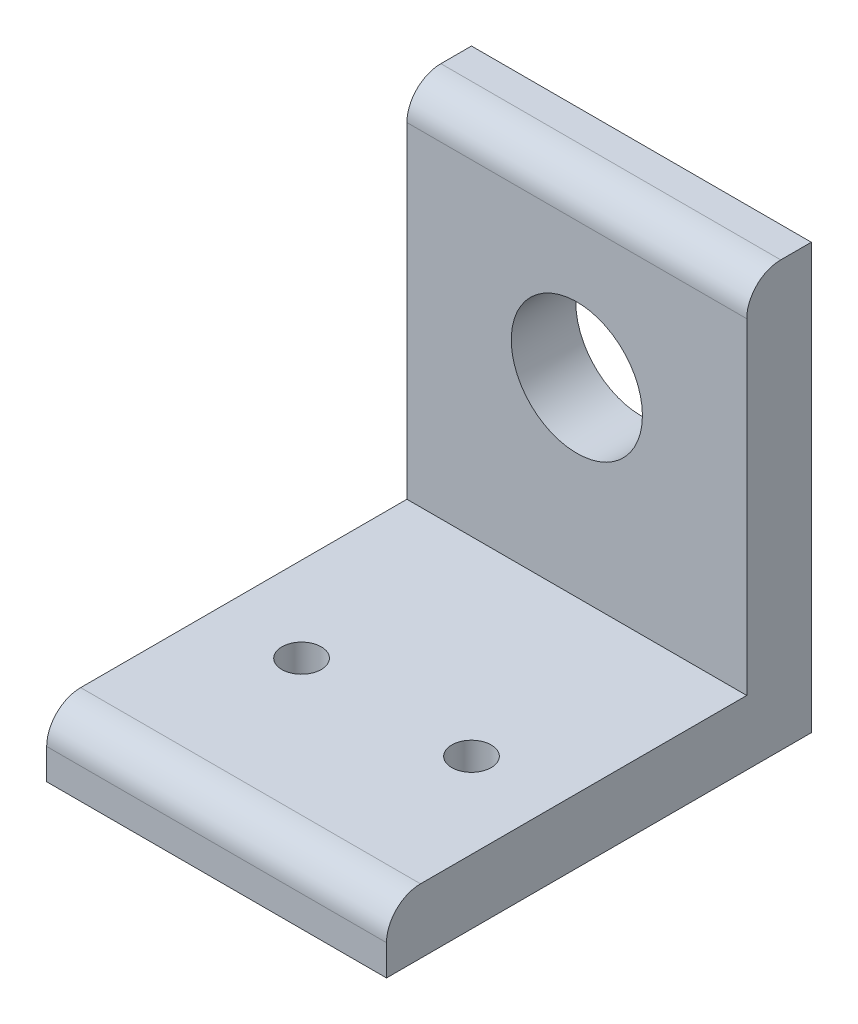
from build123d import *

# Parameters (mm, degrees)
BOSS_EXTRUDE1_DEPTH     = 50.8
SKETCH3_R               = 4.9022
CUT_EXTRUDE1_DEPTH      = 50.8
SKETCH4_R               = 1.4732
CUT_EXTRUDE2_DEPTH      = 50.8
FILLET1_R               = 2.54
SKETCH5_W               = 25.4
SKETCH5_H               = 31.75
CUT_EXTRUDE3_DEPTH      = 27.924
CUT_EXTRUDE3_DEPTH_BACK = 5.826


with BuildPart() as part:
    # Sketch2 → Boss-Extrude1 (new body)
    with BuildSketch(Plane(origin=(0, 0, 0), x_dir=(0, 0, -1), z_dir=(1, 0, 0))):
        Polygon((0, 0), (31.75, 0), (31.75, 31.75), (26.924, 31.75), (26.924, 4.826), (0, 4.826), align=None)
    extrude(amount=-BOSS_EXTRUDE1_DEPTH)

    # Sketch3 → Cut-Extrude1 (cut)
    with BuildSketch(Plane.XY.offset(-26.924)):
        with Locations((-38.1, 19.05)):
            Circle(SKETCH3_R)
        with Locations((-12.7, 19.05)):
            Circle(SKETCH3_R)
    extrude(amount=-CUT_EXTRUDE1_DEPTH, mode=Mode.SUBTRACT)

    # Sketch4 → Cut-Extrude2 (cut)
    with BuildSketch(Plane(origin=(0, 4.826, 0), x_dir=(1, 0, 0), z_dir=(0, 1, 0))):
        with Locations((-44.45, 12.7)):
            Circle(SKETCH4_R)
        with Locations((-31.75, 12.7)):
            Circle(SKETCH4_R)
    extrude(amount=-CUT_EXTRUDE2_DEPTH, mode=Mode.SUBTRACT)

    # Fillet1
    fillet1_edges = [part.edges().sort_by_distance(p)[0] for p in [
        (-25.4, 4.826, 0),
        (-25.4, 31.75, -26.924),
    ]]
    fillet(fillet1_edges, radius=FILLET1_R)

    # Sketch5 → Cut-Extrude3 (cut, two sides)
    with BuildSketch(Plane.XY.offset(-26.924)) as cut_extrude3_sk:
        with Locations((-12.7, 15.875)):
            Rectangle(SKETCH5_W, SKETCH5_H)
    extrude(amount=CUT_EXTRUDE3_DEPTH, mode=Mode.SUBTRACT)
    extrude(cut_extrude3_sk.sketch, amount=-CUT_EXTRUDE3_DEPTH_BACK, mode=Mode.SUBTRACT)


solid = part.part
